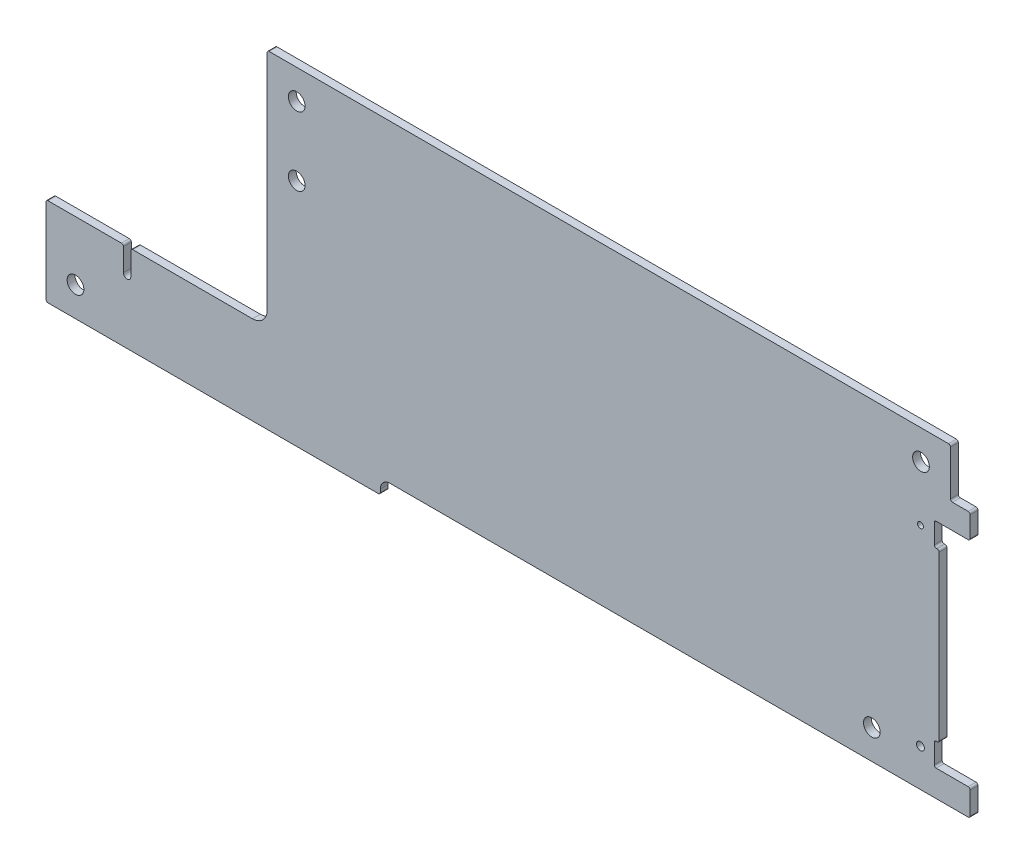
from build123d import *

# Parameters (mm, degrees)
BOSS_EXTRUDE1_DEPTH  = 1.6
SKETCH4_R            = 0.6
SKETCH4_R_2          = 0.8
CUT_EXTRUDE1_DEPTH   = 2.6
CUT_EXTRUDE2_DEPTH   = 2.6
CUT_EXTRUDE3_DEPTH   = 2.6
FILLET1_R            = 0.4
M3_CLEARANCE_HOLE1_D = 3.4


with BuildPart() as part:
    # Sketch2 → Boss-Extrude1 (new body)
    with BuildSketch(Plane.XY):
        with BuildLine():
            Line((68, -2), (68, -3))
            Line((68, -3), (0, -3))
            Line((0, -3), (0, 0))
            Line((0, 0), (0, 15))
            Line((0, 15), (42, 15))
            ThreePointArc((42, 15), (44.121320344, 15.878679656), (45, 18))
            Line((45, 18), (45, 63.8))
            Line((45, 63.8), (188, 63.8))
            Line((188, 63.8), (188, 0))
            Line((188, 0), (70, 0))
            ThreePointArc((70, 0), (68.585786438, -0.585786438), (68, -2))
        make_face()
    extrude(amount=BOSS_EXTRUDE1_DEPTH)

    # Sketch4 → Cut-Extrude1 (cut, through all)
    with BuildSketch(Plane(origin=(0, 0, 0), x_dir=(-1, 0, 0), z_dir=(0, 0, -1))):
        with Locations((-177.9, 46.591)):
            Circle(SKETCH4_R)
        with Locations((-177.9, 7.651)):
            Circle(SKETCH4_R_2)
        with BuildLine():
            Line((-188, 49.271), (-188, 48.871))
            Line((-188, 48.871), (-188, 5.371))
            Line((-188, 5.371), (-188, 4.971))
            ThreePointArc((-188, 4.971), (-187.882842712, 5.253842712), (-187.6, 5.371))
            Line((-187.6, 5.371), (-181.1, 5.371))
            ThreePointArc((-181.1, 5.371), (-180.817157288, 5.488157288), (-180.7, 5.771))
            Line((-180.7, 5.771), (-180.7, 9.721))
            ThreePointArc((-180.7, 9.721), (-180.817157288, 10.003842712), (-181.1, 10.121))
            Line((-181.1, 10.121), (-181.3, 10.121))
            ThreePointArc((-181.3, 10.121), (-181.582842712, 10.238157288), (-181.7, 10.521))
            Line((-181.7, 10.521), (-181.7, 43.721))
            ThreePointArc((-181.7, 43.721), (-181.582842712, 44.003842712), (-181.3, 44.121))
            Line((-181.3, 44.121), (-181.1, 44.121))
            ThreePointArc((-181.1, 44.121), (-180.817157288, 44.238157288), (-180.7, 44.521))
            Line((-180.7, 44.521), (-180.7, 48.471))
            ThreePointArc((-180.7, 48.471), (-180.817157288, 48.753842712), (-181.1, 48.871))
            Line((-181.1, 48.871), (-187.6, 48.871))
            ThreePointArc((-187.6, 48.871), (-187.882842712, 48.988157288), (-188, 49.271))
        make_face()
    extrude(amount=-CUT_EXTRUDE1_DEPTH, mode=Mode.SUBTRACT)

    # Sketch5 → Cut-Extrude2 (cut, through all)
    with BuildSketch(Plane.XY.offset(1.6)):
        with BuildLine():
            Line((15.75, 15), (17.25, 15))
            Line((17.25, 15), (17.25, 10))
            ThreePointArc((17.25, 10), (16.5, 9.25), (15.75, 10))
            Line((15.75, 10), (15.75, 15))
        make_face()
    extrude(amount=-CUT_EXTRUDE2_DEPTH, mode=Mode.SUBTRACT)

    # Sketch6 → Cut-Extrude3 (cut, through all)
    with BuildSketch(Plane.XY.offset(1.6)):
        with BuildLine():
            Line((188, 63.8), (184, 63.8))
            Line((184, 63.8), (184, 54.271))
            ThreePointArc((184, 54.271), (184.117157288, 53.988157288), (184.4, 53.871))
            Line((184.4, 53.871), (187.6, 53.871))
            ThreePointArc((187.6, 53.871), (187.882842712, 53.753842712), (188, 53.471))
            Line((188, 53.471), (188, 53.871))
            Line((188, 53.871), (188, 63.8))
        make_face()
    extrude(amount=-CUT_EXTRUDE3_DEPTH, mode=Mode.SUBTRACT)

    # Fillet1
    fillet1_edges = [part.edges().sort_by_distance(p)[0] for p in [
        (15.75, 15, 0.8),
        (17.25, 15, 0.8),
        (184, 63.8, 0.8),
        (0, 15, 0.8),
        (45, 63.8, 0.8),
        (188, 0, 0.8),
        (68, -3, 0.8),
        (0, -3, 0.8),
    ]]
    fillet(fillet1_edges, radius=FILLET1_R)

    # M3 Clearance Hole1 (through all)
    with Locations(Plane(origin=(0, 0, 0), x_dir=(-1, 0, 0), z_dir=(0, 0, -1))):
        with Locations((-178, 57.8), (-51, 57.8), (-6, 3), (-168, 6), (-51, 43.8)):
            Hole(M3_CLEARANCE_HOLE1_D / 2)


solid = part.part
